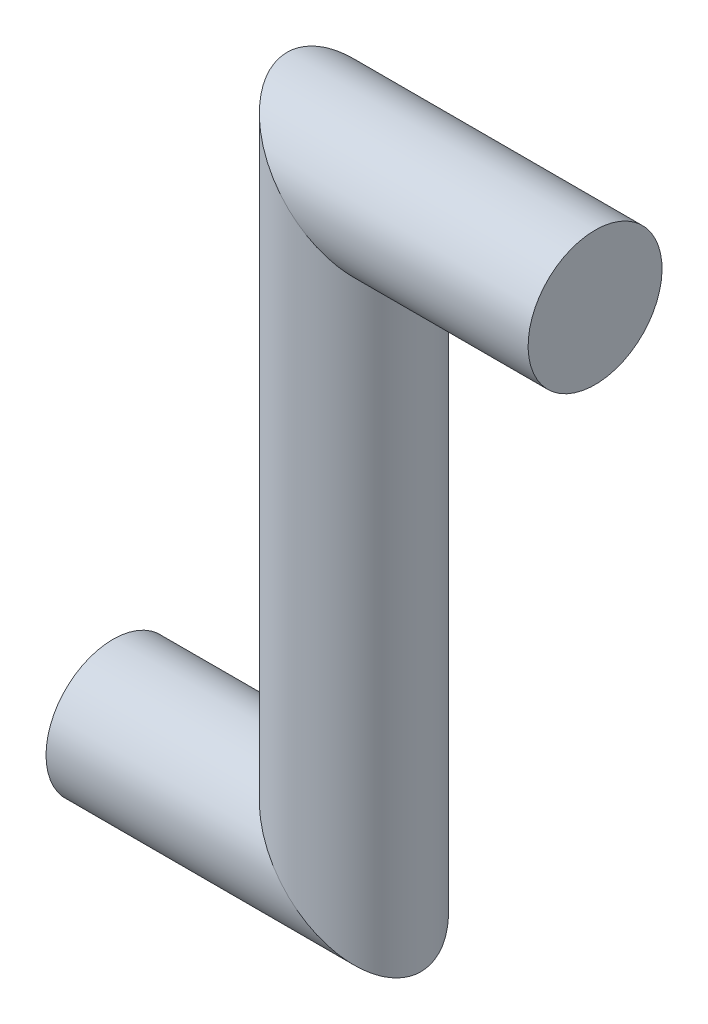
from build123d import *

# Parameters (mm, degrees)
BARRER1_PROFILE_R = 5


with BuildPart() as part:
    # Barrer1: sweep along a path in Croquis1
    with BuildLine(Plane.XY) as barrer1_path:
        Line((0, 0), (-18, 0))
        Line((-18, 0), (-18, -44.46))
        Line((-18, -44.46), (-36, -44.46))
    # Barrer1 profile (on start of the path) → Barrer1 (sweep)
    with BuildSketch(Plane(origin=(0, 0, 0), x_dir=(0, -1, 0), z_dir=(-1, 0, 0))):
        Circle(BARRER1_PROFILE_R)
    sweep(path=barrer1_path.line, transition=Transition.RIGHT)


solid = part.part
